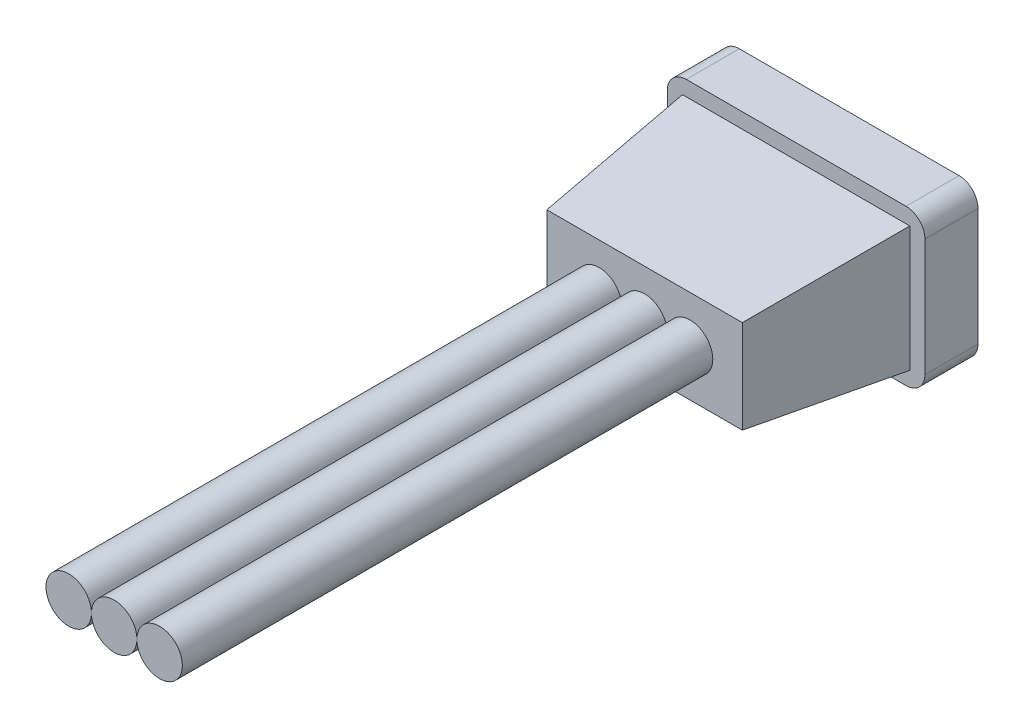
from build123d import *

# Parameters (mm, degrees)
SKETCH1_W           = 6.8
SKETCH1_H           = 4.1
BOSS_EXTRUDE1_DEPTH = 1.4
SKETCH2_W           = 6
SKETCH2_H           = 3.3
BOSS_EXTRUDE2_DEPTH = 4
BOSS_EXTRUDE2_TAPER = 6
FILLET1_R           = 0.5
SKETCH3_R           = 0.6
POSITIVE_DEPTH      = 14
SKETCH4_R           = 0.6
SIGNAL_DEPTH        = 14
SKETCH5_R           = 0.6
NEGATIVE_DEPTH      = 14


with BuildPart() as part:
    # Sketch1 → Boss-Extrude1 (new body)
    with BuildSketch(Plane.XY):
        Rectangle(SKETCH1_W, SKETCH1_H)
    extrude(amount=BOSS_EXTRUDE1_DEPTH)

    # Sketch2 → Boss-Extrude2 (add)
    with BuildSketch(Plane.XY.offset(1.4)):
        Rectangle(SKETCH2_W, SKETCH2_H)
    extrude(amount=BOSS_EXTRUDE2_DEPTH, taper=BOSS_EXTRUDE2_TAPER)

    # Fillet1
    fillet1_edges = [part.edges().sort_by_distance(p)[0] for p in [
        (3.4, -2.05, 0.7),
        (-3.4, -2.05, 0.7),
        (-3.4, 2.05, 0.7),
        (3.4, 2.05, 0.7),
    ]]
    fillet(fillet1_edges, radius=FILLET1_R)


with BuildPart() as body_2:
    # Sketch3 → POSITIVE (new body)
    with BuildSketch(Plane.XY.offset(5.4)):
        Circle(SKETCH3_R)
    extrude(amount=POSITIVE_DEPTH)


with BuildPart() as body_3:
    # Sketch4 → SIGNAL (new body)
    with BuildSketch(Plane.XY.offset(5.4)):
        with Locations((1.2, 0)):
            Circle(SKETCH4_R)
    extrude(amount=SIGNAL_DEPTH)


with BuildPart() as body_4:
    # Sketch5 → NEGATIVE (new body)
    with BuildSketch(Plane.XY.offset(5.4)):
        with Locations((-1.2, 0)):
            Circle(SKETCH5_R)
    extrude(amount=NEGATIVE_DEPTH)


solid = Compound([part.part, body_2.part, body_3.part, body_4.part])
